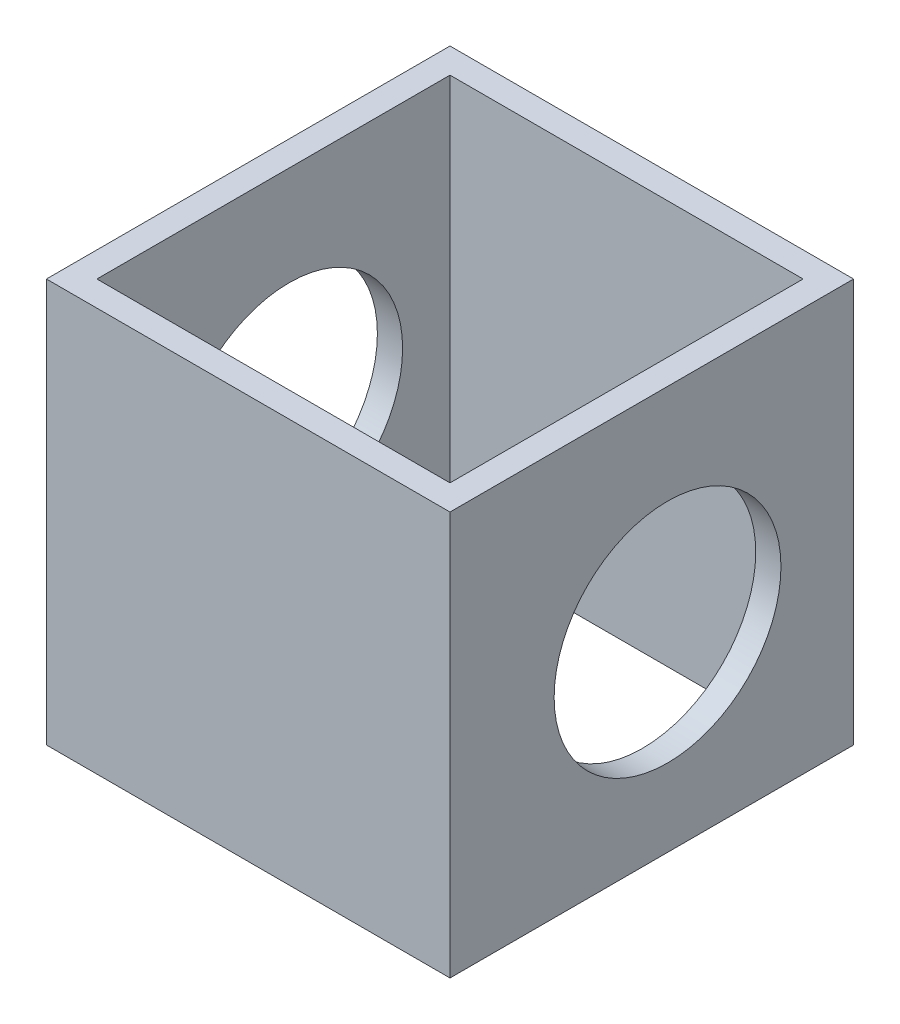
from build123d import *

# Parameters (mm, degrees)
SKETCH1_W           = 50.8
SKETCH1_H           = 50.8
SKETCH1_W_2         = 44.45
SKETCH1_H_2         = 44.45
EXTRUDE_THIN1_DEPTH = 50.8
SKETCH2_R           = 14.2748
CUT_EXTRUDE1_DEPTH  = 51.8


with BuildPart() as part:
    # Sketch1 → Extrude-Thin1 (new body)
    with BuildSketch(Plane(origin=(0, 0, 0), x_dir=(1, 0, 0), z_dir=(0, 1, 0))):
        Rectangle(SKETCH1_W, SKETCH1_H)
        Rectangle(SKETCH1_W_2, SKETCH1_H_2, mode=Mode.SUBTRACT)
    extrude(amount=EXTRUDE_THIN1_DEPTH)

    # Sketch2 → Cut-Extrude1 (cut, through all)
    with BuildSketch(Plane(origin=(25.4, 0, 0), x_dir=(0, 0, -1), z_dir=(1, 0, 0))):
        with Locations((1.984188633, 24.017111705)):
            Circle(SKETCH2_R)
    extrude(amount=-CUT_EXTRUDE1_DEPTH, mode=Mode.SUBTRACT)


solid = part.part
